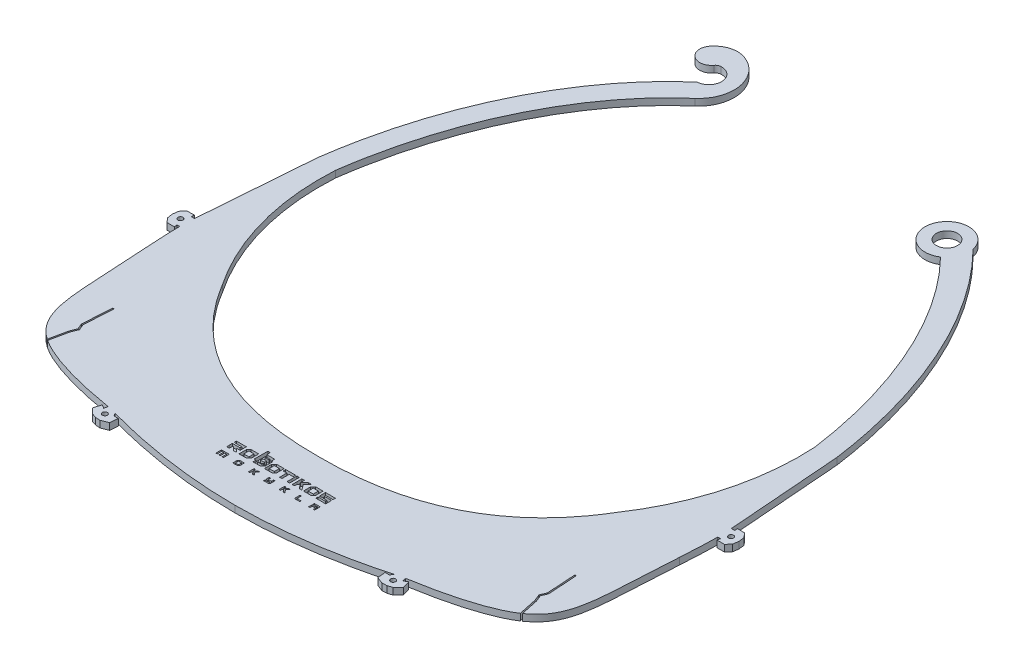
from build123d import *

# Parameters (mm, degrees)
SKETCH2_R           = 0.75
SKETCH2_R_2         = 3.169794379
BOSS_EXTRUDE2_DEPTH = 2
CUT_EXTRUDE1_DEPTH  = 1
CUT_EXTRUDE2_DEPTH  = 30


with BuildPart() as part:
    # Sketch2 → Boss-Extrude2 (new body)
    with BuildSketch(Plane(origin=(0, 0, 0), x_dir=(1, 0, 0), z_dir=(0, 1, 0))):
        with BuildLine():
            Line((-145.774014845, 4699.790846236), (-145.679424713, 4700.667060475))
            Line((-145.679424713, 4700.667060475), (-147.918372484, 4700.606196913))
            Line((-147.918372484, 4700.606196913), (-149.027988208, 4699.255761252))
            Line((-149.027988208, 4699.255761252), (-149.222790895, 4697.597182293))
            Line((-149.222790895, 4697.597182293), (-148.98298998, 4695.944509376))
            Line((-148.98298998, 4695.944509376), (-147.837087324, 4694.624725063))
            Line((-147.837087324, 4694.624725063), (-145.597312449, 4694.624725063))
            Line((-145.597312449, 4694.624725063), (-145.773758332, 4695.519138342))
            Line((-145.773758332, 4695.519138342), (-144.93974364, 4695.519138342))
            add(Edge.make_bspline(
                [(-144.46397827, 4684.514714632), (-144.606093665, 4687.588466409), (-144.901928293, 4691.324791696), (-144.93974364, 4695.519138342)],
                knots=[0.004734857, 0.004734857, 0.004734857, 0.004734857, 0.035161677, 0.035161677, 0.035161677, 0.035161677], degree=3))
            add(Edge.make_bspline(
                [(-108.903375625, 4638.035656948), (-118.821969125, 4639.685871765), (-132.493488743, 4643.060373116), (-144.218775593, 4654.394416396), (-143.099113193, 4666.334603474), (-144.46397827, 4684.514714632)],
                knots=[0.018902136, 0.018902136, 0.018902136, 0.018902136, 0.394121885, 0.490994555, 0.987628845, 0.987628845, 0.987628845, 0.987628845], degree=3))
            Line((-108.903375625, 4638.035656948), (-109.111012106, 4636.936921529))
            Line((-109.111012106, 4636.936921529), (-110.228421491, 4637.612566847))
            Line((-110.228421491, 4637.612566847), (-110.904437831, 4635.297018365))
            Line((-110.904437831, 4635.297018365), (-109.31209767, 4633.795971308))
            Line((-109.31209767, 4633.795971308), (-107.959504664, 4633.340434244))
            Line((-107.959504664, 4633.340434244), (-106.534299374, 4633.264199495))
            Line((-106.534299374, 4633.264199495), (-104.500152189, 4634.07100473))
            Line((-104.500152189, 4634.07100473), (-104.273152305, 4636.472511323))
            Line((-104.273152305, 4636.472511323), (-105.57754023, 4636.472511323))
            Line((-105.57754023, 4636.472511323), (-106.108269156, 4637.355076027))
            add(Edge.make_bspline(
                [(-64.303390576, 4631.426207785), (-78.229594734, 4631.453371402), (-92.531802759, 4633.559092847), (-106.108269156, 4637.355076027)],
                knots=[0.500293183, 0.500293183, 0.500293183, 0.500293183, 0.981944699, 0.981944699, 0.981944699, 0.981944699], degree=3))
            add(Edge.make_bspline(
                [(-64.303390576, 4631.426207785), (-50.377186419, 4631.453371402), (-36.074978393, 4633.559092847), (-22.498511996, 4637.355076027)],
                knots=[0.500293183, 0.500293183, 0.500293183, 0.500293183, 0.981944699, 0.981944699, 0.981944699, 0.981944699], degree=3))
            Line((-22.498511996, 4637.355076027), (-23.029240922, 4636.472511323))
            Line((-23.029240922, 4636.472511323), (-24.333628848, 4636.472511323))
            Line((-24.333628848, 4636.472511323), (-24.106628964, 4634.07100473))
            Line((-24.106628964, 4634.07100473), (-22.072481779, 4633.264199495))
            Line((-22.072481779, 4633.264199495), (-20.647276489, 4633.340434244))
            Line((-20.647276489, 4633.340434244), (-19.294683483, 4633.795971308))
            Line((-19.294683483, 4633.795971308), (-17.702343322, 4635.297018365))
            Line((-17.702343322, 4635.297018365), (-18.378359662, 4637.612566847))
            Line((-18.378359662, 4637.612566847), (-19.495769046, 4636.936921529))
            Line((-19.495769046, 4636.936921529), (-19.703405528, 4638.035656948))
            add(Edge.make_bspline(
                [(-19.703405528, 4638.035656948), (-9.784812028, 4639.685871765), (3.88670759, 4643.060373116), (15.611994441, 4654.394416396), (14.49233204, 4666.334603474), (15.857197118, 4684.514714632)],
                knots=[0.018902136, 0.018902136, 0.018902136, 0.018902136, 0.394121885, 0.490994555, 0.987628845, 0.987628845, 0.987628845, 0.987628845], degree=3))
            add(Edge.make_bspline(
                [(15.857197118, 4684.514714632), (15.999312513, 4687.588466409), (16.29514714, 4691.324791696), (16.332962487, 4695.519138342)],
                knots=[0.004734857, 0.004734857, 0.004734857, 0.004734857, 0.035161677, 0.035161677, 0.035161677, 0.035161677], degree=3))
            Line((16.332962487, 4695.519138342), (17.166977179, 4695.519138342))
            Line((17.166977179, 4695.519138342), (16.990531296, 4694.624725063))
            Line((16.990531296, 4694.624725063), (19.230306172, 4694.624725063))
            Line((19.230306172, 4694.624725063), (20.376208827, 4695.944509376))
            Line((20.376208827, 4695.944509376), (20.616009742, 4697.597182293))
            Line((20.616009742, 4697.597182293), (20.421207056, 4699.255761252))
            Line((20.421207056, 4699.255761252), (19.311591332, 4700.606196913))
            Line((19.311591332, 4700.606196913), (17.072643561, 4700.667060475))
            Line((17.072643561, 4700.667060475), (17.167233693, 4699.790846236))
            Line((17.167233693, 4699.790846236), (16.143581312, 4699.790846236))
            Line((16.143581312, 4699.790846236), (13.505704616, 4734.046734393))
            add(Edge.make_bspline(
                [(-20.140377949, 4808.505435192), (-19.339215101, 4807.69878822), (-16.169205429, 4804.385156989), (-10.959428961, 4798.073334595), (-4.937431717, 4789.049110006), (0.359464838, 4779.225886251), (4.896611241, 4768.706679247), (8.641256086, 4757.60156043), (11.078840538, 4747.950225277), (12.60715411, 4740.056303981), (13.230863748, 4736.050334581), (13.505704616, 4734.046734393)],
                knots=[-2.547822097, -2.547822097, -2.547822097, -2.547822097, -2.512682102, -2.406957035, -2.301231967, -2.1955069, -2.089781833, -1.984056766, -1.878331699, -1.825469165, -1.772606631, -1.772606631, -1.772606631, -1.772606631], degree=3))
            ThreePointArc((-20.140377949, 4808.505435192), (-32.664266502, 4809.623514522), (-22.989188291, 4801.592901377))
            add(Edge.make_bspline(
                [(7.531205359, 4733.448618243), (1.49518461, 4776.711269913), (-22.989188291, 4801.592901377)],
                knots=[1.775964024, 1.775964024, 1.775964024, 2.543499924, 2.543499924, 2.543499924], degree=2, weights=[1, 0.927260437, 1]))
            ThreePointArc((7.531205359, 4733.448618243), (4.986516441, 4708.998918893), (-5.29304341, 4686.669702846))
            add(Edge.make_bspline(
                [(-64.303390576, 4656.572608608), (-23.423446833, 4656.293379669), (-5.29304341, 4686.669702846)],
                knots=[0, 0, 0, 1, 1, 1], degree=2))
            add(Edge.make_bspline(
                [(-64.303390576, 4656.572608608), (-105.18333432, 4656.293379669), (-123.313737743, 4686.669702846)],
                knots=[0, 0, 0, 1, 1, 1], degree=2))
            ThreePointArc((-123.313737743, 4686.669702846), (-133.593297594, 4708.998918893), (-136.137986511, 4733.448618243))
            add(Edge.make_bspline(
                [(-100.963860647, 4805.950790548), (-129.440493439, 4781.452315035), (-136.137986511, 4733.448618243)],
                knots=[3.66477814, 3.66477814, 3.66477814, 4.507221283, 4.507221283, 4.507221283], degree=2, weights=[1, 0.912590151, 1]))
            ThreePointArc((-100.963860647, 4805.950790548), (-97.422627424, 4815.929347659), (-104.224712723, 4824.043752771))
            ThreePointArc((-104.224712723, 4824.043752771), (-108.705347231, 4824.182862669), (-112.368006092, 4821.59822203))
            ThreePointArc((-112.368006092, 4821.59822203), (-111.611928523, 4816.659274376), (-106.672980869, 4817.415351945))
            ThreePointArc((-106.672980869, 4817.415351945), (-106.103107375, 4817.914471202), (-105.375761358, 4818.126234287))
            ThreePointArc((-105.375761358, 4818.126234287), (-101.312817548, 4814.562168737), (-104.876883098, 4810.499224928))
            add(Edge.make_bspline(
                [(-104.876883098, 4810.499224928), (-106.096560831, 4809.44993496), (-108.458644854, 4807.290890126), (-113.03760026, 4802.595468236), (-118.390037321, 4796.115503959), (-124.190014325, 4787.432936271), (-129.311920423, 4777.946809151), (-133.714255465, 4767.757887709), (-137.358438688, 4756.975851357), (-139.737248923, 4747.587905934), (-141.231816337, 4739.902065904), (-141.842982215, 4735.998688424), (-142.112485768, 4734.046734393)],
                knots=[-2.618407168, -2.618407168, -2.618407168, -2.618407168, -2.5656247, -2.512842233, -2.407277298, -2.301712363, -2.196147428, -2.090582493, -1.985017558, -1.879452622, -1.826670155, -1.773887687, -1.773887687, -1.773887687, -1.773887687], degree=3))
            Line((-142.112485768, 4734.046734393), (-144.750362465, 4699.790846236))
            Line((-144.750362465, 4699.790846236), (-145.774014845, 4699.790846236))
        make_face()
        with Locations((-146.82022248, 4697.629831976)):
            Circle(SKETCH2_R, mode=Mode.SUBTRACT)
        with Locations((-107.515119617, 4635.661753265)):
            Circle(SKETCH2_R, mode=Mode.SUBTRACT)
        with Locations((-21.091661535, 4635.661753265)):
            Circle(SKETCH2_R, mode=Mode.SUBTRACT)
        with Locations((18.213441328, 4697.629831976)):
            Circle(SKETCH2_R, mode=Mode.SUBTRACT)
        with Locations((-26.576401525, 4807.114568719)):
            Circle(SKETCH2_R_2, mode=Mode.SUBTRACT)
    extrude(amount=BOSS_EXTRUDE2_DEPTH)

    # Sketch3 → Cut-Extrude1 (cut)
    with BuildSketch(Plane(origin=(0, 2, 0), x_dir=(1, 0, 0), z_dir=(0, 1, 0))):
        Polygon((-80.67831347, 4642.941212701), (-80.67831347, 4643.793212801), (-79.52631347, 4643.793212801), (-78.37431317, 4643.793212801), (-78.37431317, 4642.941212701), (-78.37431317, 4642.089212901), (-78.57831327, 4642.089212901), (-78.78231337, 4642.089212901), (-78.78231337, 4642.761212701), (-78.78231337, 4643.433212801), (-79.05831317, 4643.433212801), (-79.33431327, 4643.433212801), (-79.33431327, 4642.761212701), (-79.33431327, 4642.089212901), (-79.53831337, 4642.089212901), (-79.74231347, 4642.089212901), (-79.74231347, 4642.761212701), (-79.74231347, 4643.433212801), (-80.00631337, 4643.433212801), (-80.27031327, 4643.433212801), (-80.27031327, 4642.761212701), (-80.27031327, 4642.089212901), (-80.47431337, 4642.089212901), (-80.67831347, 4642.089212901), align=None)
        Polygon((-75.59031337, 4642.755775801), (-75.59031337, 4643.422338801), (-75.40378227, 4643.607775901), (-75.21725127, 4643.793212801), (-74.52778237, 4643.793212801), (-73.83831327, 4643.793212801), (-73.83831327, 4643.114611901), (-73.83831327, 4642.436011401), (-74.01287777, 4642.262612101), (-74.18744177, 4642.089212901), (-74.88887767, 4642.089212901), (-75.59031337, 4642.089212901), align=None)
        Polygon((-74.25831337, 4642.941212701), (-74.25831337, 4643.421212901), (-74.72031327, 4643.427729701), (-75.18231317, 4643.434249401), (-75.18231317, 4642.941212701), (-75.18231317, 4642.448176201), (-74.72031327, 4642.454695901), (-74.25831337, 4642.461212801), align=None, mode=Mode.SUBTRACT)
        with BuildLine():
            Line((-70.93431317, 4642.941212701), (-70.93431317, 4643.793212801))
            Line((-70.93431317, 4643.793212801), (-70.70631327, 4643.793212801))
            Line((-70.70631327, 4643.793212801), (-70.47831307, 4643.793212801))
            Line((-70.47831307, 4643.793212801), (-70.47831307, 4643.427503201))
            Line((-70.47831307, 4643.427503201), (-70.47831307, 4643.061793701))
            Line((-70.47831307, 4643.061793701), (-70.11203147, 4643.427503201))
            Line((-70.11203147, 4643.427503201), (-69.74574987, 4643.793212801))
            Line((-69.74574987, 4643.793212801), (-69.47106907, 4643.793212801))
            Line((-69.47106907, 4643.793212801), (-69.19638817, 4643.793212801))
            Line((-69.19638817, 4643.793212801), (-69.54935057, 4643.437411701))
            add(Edge.make_bspline(
                [(-69.54935057, 4643.437411701), (-69.74347987, 4643.241721401), (-69.90231307, 4643.074049301), (-69.90231307, 4643.064807501)],
                knots=[0, 0, 0, 0, 1, 1, 1, 1], degree=3))
            add(Edge.make_bspline(
                [(-69.90231307, 4643.064807501), (-69.90231307, 4643.055566501), (-69.74010867, 4642.832276101), (-69.54185867, 4642.568608401)],
                knots=[0, 0, 0, 0, 1, 1, 1, 1], degree=3))
            Line((-69.54185867, 4642.568608401), (-69.18140427, 4642.089212901))
            Line((-69.18140427, 4642.089212901), (-69.43985877, 4642.089921501))
            Line((-69.43985877, 4642.089921501), (-69.69831297, 4642.090630201))
            Line((-69.69831297, 4642.090630201), (-69.92631317, 4642.402879501))
            add(Edge.make_bspline(
                [(-69.92631317, 4642.402879501), (-70.05171307, 4642.574616801), (-70.16793917, 4642.733138401), (-70.18459387, 4642.755149901)],
                knots=[0, 0, 0, 0, 1, 1, 1, 1], degree=3))
            add(Edge.make_bspline(
                [(-70.18459387, 4642.755149901), (-70.21166477, 4642.790927701), (-70.23011207, 4642.780092001), (-70.35859377, 4642.652951301)],
                knots=[0, 0, 0, 0, 1, 1, 1, 1], degree=3))
            Line((-70.35859377, 4642.652951301), (-70.50231317, 4642.510731501))
            Line((-70.50231317, 4642.510731501), (-70.50231317, 4642.299980101))
            Line((-70.50231317, 4642.299980101), (-70.50231317, 4642.089229001))
            Line((-70.50231317, 4642.089229001), (-70.71831317, 4642.089229001))
            Line((-70.71831317, 4642.089229001), (-70.93431317, 4642.089229001))
            Line((-70.93431317, 4642.089229001), (-70.93431317, 4642.941212701))
        make_face()
        Polygon((-66.37431307, 4642.281212801), (-66.37431307, 4642.473212701), (-65.70231297, 4642.473212701), (-65.03031287, 4642.473212701), (-65.03031287, 4642.605212801), (-65.03031287, 4642.737212901), (-65.70231297, 4642.737212901), (-66.37431307, 4642.737212901), (-66.37431307, 4643.265212701), (-66.37431307, 4643.793212801), (-66.15831307, 4643.793212801), (-65.94231307, 4643.793212801), (-65.94231307, 4643.445212701), (-65.94231307, 4643.097212901), (-65.48631297, 4643.097212901), (-65.03031287, 4643.097212901), (-65.03031287, 4643.445212701), (-65.03031287, 4643.793212801), (-64.82631307, 4643.793212801), (-64.62231297, 4643.793212801), (-64.62231297, 4643.126649801), (-64.62231297, 4642.460086601), (-64.80884367, 4642.274649701), (-64.99537497, 4642.089212901), (-65.68484387, 4642.089212901), (-66.37431307, 4642.089212901), align=None)
        with BuildLine():
            Line((-61.76631307, 4642.941212701), (-61.76631307, 4643.793212801))
            Line((-61.76631307, 4643.793212801), (-61.53831397, 4643.793212801))
            Line((-61.53831397, 4643.793212801), (-61.31031207, 4643.793212801))
            Line((-61.31031207, 4643.793212801), (-61.31031207, 4643.431095001))
            Line((-61.31031207, 4643.431095001), (-61.31031207, 4643.068977301))
            Line((-61.31031207, 4643.068977301), (-60.93231207, 4643.430671201))
            Line((-60.93231207, 4643.430671201), (-60.55431207, 4643.792365201))
            Line((-60.55431207, 4643.792365201), (-60.29417947, 4643.792790401))
            Line((-60.29417947, 4643.792790401), (-60.03404977, 4643.793215601))
            Line((-60.03404977, 4643.793215601), (-60.37818137, 4643.430185701))
            add(Edge.make_bspline(
                [(-60.37818137, 4643.430185701), (-60.56745347, 4643.230519501), (-60.71943307, 4643.057179501), (-60.71591237, 4643.044985701)],
                knots=[0, 0, 0, 0, 1, 1, 1, 1], degree=3))
            add(Edge.make_bspline(
                [(-60.71591237, 4643.044985701), (-60.71106517, 4643.028196101), (-60.18086737, 4642.310719701), (-60.03178767, 4642.119215601)],
                knots=[0, 0, 0, 0, 1, 1, 1, 1], degree=3))
            add(Edge.make_bspline(
                [(-60.03178767, 4642.119215601), (-60.01341917, 4642.095634201), (-60.06285537, 4642.089215401), (-60.26281417, 4642.089215401)],
                knots=[0, 0, 0, 0, 1, 1, 1, 1], degree=3))
            Line((-60.26281417, 4642.089215401), (-60.51718957, 4642.089215401))
            Line((-60.51718957, 4642.089215401), (-60.76060627, 4642.419215501))
            add(Edge.make_bspline(
                [(-60.76060627, 4642.419215501), (-60.89448657, 4642.600715601), (-61.01153197, 4642.757467301), (-61.02070767, 4642.767552901)],
                knots=[0, 0, 0, 0, 1, 1, 1, 1], degree=3))
            add(Edge.make_bspline(
                [(-61.02070767, 4642.767552901), (-61.02989197, 4642.777638601), (-61.10419647, 4642.725432401), (-61.18585127, 4642.651539101)],
                knots=[0, 0, 0, 0, 1, 1, 1, 1], degree=3))
            Line((-61.18585127, 4642.651539101), (-61.33431307, 4642.517186301))
            Line((-61.33431307, 4642.517186301), (-61.33431307, 4642.303200001))
            Line((-61.33431307, 4642.303200001), (-61.33431307, 4642.089213701))
            Line((-61.33431307, 4642.089213701), (-61.55031307, 4642.089213701))
            Line((-61.55031307, 4642.089213701), (-61.76631307, 4642.089213701))
            Line((-61.76631307, 4642.089213701), (-61.76631307, 4642.941212701))
        make_face()
        Polygon((-57.13431207, 4642.941212701), (-57.13431207, 4643.793212801), (-56.93031397, 4643.793212801), (-56.72631307, 4643.793212801), (-56.72631307, 4643.133212901), (-56.72631307, 4642.473212701), (-56.12631207, 4642.473212701), (-55.52631397, 4642.473212701), (-55.52631397, 4642.281212801), (-55.52631397, 4642.089212901), (-56.33031307, 4642.089212901), (-57.13431207, 4642.089212901), align=None)
        Polygon((-52.83831307, 4642.593212901), (-52.83831307, 4643.097212901), (-52.17831117, 4643.097212901), (-51.51831207, 4643.097212901), (-51.51831207, 4643.241212901), (-51.51831207, 4643.385212901), (-52.17831117, 4643.385212901), (-52.83831307, 4643.385212901), (-52.83831307, 4643.589212701), (-52.83831307, 4643.793212801), (-51.96231117, 4643.793212801), (-51.08631207, 4643.793212801), (-51.08631207, 4642.941212701), (-51.08631207, 4642.089212901), (-51.27831117, 4642.089212901), (-51.47031307, 4642.089212901), (-51.47031307, 4642.413212901), (-51.47031307, 4642.737212901), (-51.93831307, 4642.737212901), (-52.40631307, 4642.737212901), (-52.40631307, 4642.413212901), (-52.40631307, 4642.089212901), (-52.62231307, 4642.089212901), (-52.83831307, 4642.089212901), align=None)
        with BuildLine():
            Line((-80.72631227, 4646.257212901), (-80.72631227, 4647.105212801))
            Line((-80.72631227, 4647.105212801), (-79.57431227, 4647.105212801))
            Line((-79.57431227, 4647.105212801), (-78.42231227, 4647.105212801))
            Line((-78.42231227, 4647.105212801), (-78.42231227, 4647.356980101))
            Line((-78.42231227, 4647.356980101), (-78.42231227, 4647.608747301))
            Line((-78.42231227, 4647.608747301), (-79.56831217, 4647.614980701))
            Line((-79.56831217, 4647.614980701), (-80.71431227, 4647.621214101))
            Line((-80.71431227, 4647.621214101), (-80.72097087, 4647.963214101))
            Line((-80.72097087, 4647.963214101), (-80.72762947, 4648.305214101))
            Line((-80.72762947, 4648.305214101), (-79.23897057, 4648.305214101))
            Line((-79.23897057, 4648.305214101), (-77.75031157, 4648.305214101))
            Line((-77.75031157, 4648.305214101), (-77.75031157, 4647.365421401))
            Line((-77.75031157, 4647.365421401), (-77.75031157, 4646.425628901))
            Line((-77.75031157, 4646.425628901), (-78.28321507, 4646.440524901))
            Line((-78.28321507, 4646.440524901), (-78.81611847, 4646.455421001))
            Line((-78.81611847, 4646.455421001), (-78.27741507, 4645.916318501))
            Line((-78.27741507, 4645.916318501), (-77.73871167, 4645.377215601))
            Line((-77.73871167, 4645.377215601), (-78.20429907, 4645.377215601))
            Line((-78.20429907, 4645.377215601), (-78.66988447, 4645.377215601))
            Line((-78.66988447, 4645.377215601), (-79.20124337, 4645.905212901))
            add(Edge.make_bspline(
                [(-79.20124337, 4645.905212901), (-79.70063397, 4646.401446801), (-79.73791947, 4646.433212701), (-79.82098957, 4646.433212701)],
                knots=[0, 0, 0, 0, 1, 1, 1, 1], degree=3))
            Line((-79.82098957, 4646.433212701), (-79.90937727, 4646.433212701))
            Line((-79.90937727, 4646.433212701), (-79.91584597, 4645.911212701))
            Line((-79.91584597, 4645.911212701), (-79.92231457, 4645.389212701))
            Line((-79.92231457, 4645.389212701), (-80.30774197, 4645.382639101))
            add(Edge.make_bspline(
                [(-80.30774197, 4645.382639101), (-80.51972697, 4645.379025001), (-80.70062697, 4645.383517901), (-80.70974087, 4645.392640101)],
                knots=[0, 0, 0, 0, 1, 1, 1, 1], degree=3))
            add(Edge.make_bspline(
                [(-80.70974087, 4645.392640101), (-80.71885427, 4645.401756301), (-80.72631227, 4645.790812501), (-80.72631227, 4646.257212901)],
                knots=[0, 0, 0, 0, 1, 1, 1, 1], degree=3))
        make_face()
        Polygon((-77.00631317, 4646.475503101), (-77.00631317, 4647.573793601), (-76.64003157, 4647.939503101), (-76.27375027, 4648.305212701), (-75.15203177, 4648.305212701), (-74.03031317, 4648.305212701), (-74.03031317, 4647.218931401), (-74.03031317, 4646.132650101), (-74.40858607, 4645.754931601), (-74.78685907, 4645.377212801), (-75.89658597, 4645.377212801), (-77.00631317, 4645.377212801), align=None)
        Polygon((-74.75031317, 4646.841212601), (-74.75031317, 4647.609212801), (-75.51831337, 4647.609212801), (-76.28631317, 4647.609212801), (-76.28631317, 4646.841212601), (-76.28631317, 4646.073212701), (-75.51831337, 4646.073212701), (-74.75031317, 4646.073212701), align=None, mode=Mode.SUBTRACT)
        Polygon((-69.39831307, 4646.475503101), (-69.39831307, 4647.573793601), (-69.03203147, 4647.939503101), (-68.66574987, 4648.305212701), (-67.54403157, 4648.305212701), (-66.42231297, 4648.305212701), (-66.42231297, 4647.218931401), (-66.42231297, 4646.132650101), (-66.80058587, 4645.754931601), (-67.17885857, 4645.377212801), (-68.28858587, 4645.377212801), (-69.39831307, 4645.377212801), align=None)
        Polygon((-67.14231297, 4646.841212601), (-67.14231297, 4647.609212801), (-67.91031317, 4647.609212801), (-68.67831307, 4647.609212801), (-68.67831307, 4646.841212601), (-68.67831307, 4646.073212701), (-67.91031317, 4646.073212701), (-67.14231297, 4646.073212701), align=None, mode=Mode.SUBTRACT)
        Polygon((-64.86231307, 4646.469212701), (-64.86231307, 4647.561212601), (-65.41431297, 4647.561212601), (-65.96631287, 4647.561212601), (-65.96631287, 4647.933212801), (-65.96631287, 4648.305212701), (-64.47831297, 4648.305212701), (-62.99031277, 4648.305212701), (-62.99031277, 4647.933212801), (-62.99031277, 4647.561212601), (-63.57831297, 4647.561212601), (-64.16631287, 4647.561212601), (-64.16631287, 4646.469212701), (-64.16631287, 4645.377212801), (-64.51431297, 4645.377212801), (-64.86231307, 4645.377212801), align=None)
        Polygon((-62.60631297, 4646.840603401), (-62.60631297, 4648.305212701), (-62.22212687, 4648.305212701), (-61.83794167, 4648.305212701), (-61.84412127, 4646.847212701), (-61.85030077, 4645.389212701), (-62.22830157, 4645.382602301), (-62.60630157, 4645.375991901), align=None)
        with BuildLine():
            Line((-61.09431207, 4646.840579301), (-61.09431207, 4648.305212701))
            Line((-61.09431207, 4648.305212701), (-60.72271837, 4648.305212701))
            Line((-60.72271837, 4648.305212701), (-60.35112187, 4648.305212701))
            Line((-60.35112187, 4648.305212701), (-60.34471557, 4647.691607101))
            Line((-60.34471557, 4647.691607101), (-60.33830927, 4647.078001901))
            Line((-60.33830927, 4647.078001901), (-59.70990797, 4647.692154801))
            Line((-59.70990797, 4647.692154801), (-59.08150677, 4648.306308001))
            Line((-59.08150677, 4648.306308001), (-58.64190707, 4648.299759901))
            Line((-58.64190707, 4648.299759901), (-58.20231017, 4648.293211901))
            Line((-58.20231017, 4648.293211901), (-58.81347397, 4647.674236401))
            add(Edge.make_bspline(
                [(-58.81347397, 4647.674236401), (-59.38789787, 4647.092471301), (-59.42272717, 4647.052200101), (-59.39283867, 4647.004342501)],
                knots=[0, 0, 0, 0, 1, 1, 1, 1], degree=3))
            add(Edge.make_bspline(
                [(-59.39283867, 4647.004342501), (-59.37534897, 4646.976336201), (-59.10302457, 4646.609749001), (-58.78767587, 4646.189701901)],
                knots=[0, 0, 0, 0, 1, 1, 1, 1], degree=3))
            add(Edge.make_bspline(
                [(-58.78767587, 4646.189701901), (-58.47232437, 4645.769654701), (-58.21430927, 4645.415006801), (-58.21430927, 4645.401595601)],
                knots=[0, 0, 0, 0, 1, 1, 1, 1], degree=3))
            add(Edge.make_bspline(
                [(-58.21430927, 4645.401595601), (-58.21430927, 4645.386109901), (-58.35319837, 4645.377211901), (-58.59495677, 4645.377211901)],
                knots=[0, 0, 0, 0, 1, 1, 1, 1], degree=3))
            Line((-58.59495677, 4645.377211901), (-58.97560437, 4645.377211901))
            Line((-58.97560437, 4645.377211901), (-59.42895777, 4645.988569301))
            add(Edge.make_bspline(
                [(-59.42895777, 4645.988569301), (-59.67830167, 4646.324816101), (-59.89026797, 4646.600216101), (-59.89999647, 4646.600569301)],
                knots=[0, 0, 0, 0, 1, 1, 1, 1], degree=3))
            add(Edge.make_bspline(
                [(-59.89999647, 4646.600569301), (-59.90971937, 4646.600909501), (-60.01772217, 4646.506711901), (-60.13999457, 4646.391211701)],
                knots=[0, 0, 0, 0, 1, 1, 1, 1], degree=3))
            Line((-60.13999457, 4646.391211701), (-60.36231017, 4646.181211801))
            Line((-60.36231017, 4646.181211801), (-60.37430077, 4645.785211801))
            Line((-60.37430077, 4645.785211801), (-60.38629127, 4645.389211801))
            Line((-60.38629127, 4645.389211801), (-60.74029037, 4645.382570301))
            Line((-60.74029037, 4645.382570301), (-61.09428937, 4645.375928701))
            Line((-61.09428937, 4645.375928701), (-61.09431207, 4646.840579301))
        make_face()
        Polygon((-57.71031207, 4646.475511301), (-57.71031207, 4647.573801501), (-57.34403047, 4647.939511301), (-56.97774897, 4648.305212701), (-55.85603147, 4648.305212701), (-54.73431397, 4648.305212701), (-54.73431397, 4647.218931401), (-54.73431397, 4646.132650101), (-55.11258607, 4645.754931601), (-55.49085827, 4645.377212801), (-56.60058517, 4645.377212801), (-57.71031207, 4645.377212801), align=None)
        Polygon((-55.45431397, 4646.841212601), (-55.45431397, 4647.609212801), (-56.22231307, 4647.609212801), (-56.99031207, 4647.609212801), (-56.99031207, 4646.841212601), (-56.99031207, 4646.073212701), (-56.22231307, 4646.073212701), (-55.45431397, 4646.073212701), align=None, mode=Mode.SUBTRACT)
        with BuildLine():
            Line((-54.01432817, 4645.717212901), (-54.01432817, 4646.025212801))
            Line((-54.01432817, 4646.025212801), (-52.87432717, 4646.025212801))
            Line((-52.87432717, 4646.025212801), (-51.73432627, 4646.025212801))
            Line((-51.73432627, 4646.025212801), (-51.73432627, 4646.240977801))
            Line((-51.73432627, 4646.240977801), (-51.73432627, 4646.456742801))
            Line((-51.73432627, 4646.456742801), (-52.86832627, 4646.462979001))
            Line((-52.86832627, 4646.462979001), (-54.00232627, 4646.469212401))
            Line((-54.00232627, 4646.469212401), (-54.00861917, 4647.387212401))
            Line((-54.00861917, 4647.387212401), (-54.01491207, 4648.305212401))
            Line((-54.01491207, 4648.305212401), (-52.52662677, 4648.305212401))
            Line((-52.52662677, 4648.305212401), (-51.03834137, 4648.305212401))
            Line((-51.03834137, 4648.305212401), (-51.03834137, 4647.933212501))
            Line((-51.03834137, 4647.933212501), (-51.03834137, 4647.561212301))
            Line((-51.03834137, 4647.561212301), (-52.13034047, 4647.561212301))
            Line((-52.13034047, 4647.561212301), (-53.22233947, 4647.561212301))
            Line((-53.22233947, 4647.561212301), (-53.22233947, 4647.357212501))
            Line((-53.22233947, 4647.357212501), (-53.22233947, 4647.153212401))
            Line((-53.22233947, 4647.153212401), (-52.13034047, 4647.153212401))
            Line((-52.13034047, 4647.153212401), (-51.03834137, 4647.153212401))
            Line((-51.03834137, 4647.153212401), (-51.03834137, 4646.265212301))
            Line((-51.03834137, 4646.265212301), (-51.03834137, 4645.377212501))
            Line((-51.03834137, 4645.377212501), (-52.51033887, 4645.377212501))
            add(Edge.make_bspline(
                [(-52.51033887, 4645.377212501), (-53.31994197, 4645.377212501), (-53.98954197, 4645.384412501), (-53.99834077, 4645.393211201)],
                knots=[0, 0, 0, 0, 1, 1, 1, 1], degree=3))
            add(Edge.make_bspline(
                [(-53.99834077, 4645.393211201), (-54.00712817, 4645.402011701), (-54.01432817, 4645.547812501), (-54.01432817, 4645.717212901)],
                knots=[0, 0, 0, 0, 1, 1, 1, 1], degree=3))
        make_face()
        Polygon((-72.83031327, 4645.833212901), (-72.83031327, 4646.265212601), (-73.10644707, 4646.265212601), (-73.38258127, 4646.265212601), (-73.37644707, 4648.323212701), (-73.37031297, 4650.381212801), (-73.00431287, 4650.387837301), (-72.63831277, 4650.394461901), (-72.63831277, 4649.865837001), (-72.63831277, 4649.337211901), (-71.46231297, 4649.337211901), (-70.28631287, 4649.337211901), (-70.28631287, 4648.833211901), (-70.28631287, 4648.329211901), (-70.09431267, 4648.329211901), (-69.90231277, 4648.329211901), (-69.90231277, 4647.194890201), (-69.90231277, 4646.060569001), (-70.23262327, 4645.730890401), (-70.56293427, 4645.401212001), (-71.69662337, 4645.401212001), (-72.83031297, 4645.401212001), align=None)
        with BuildLine():
            Line((-70.79031317, 4646.469212701), (-70.99325337, 4646.265212601))
            Line((-70.99325337, 4646.265212601), (-71.55178317, 4646.265212601))
            Line((-71.55178317, 4646.265212601), (-72.11031327, 4646.265212601))
            Line((-72.11031327, 4646.265212601), (-72.11031327, 4646.169212801))
            Line((-72.11031327, 4646.169212801), (-72.11031327, 4646.073212701))
            Line((-72.11031327, 4646.073212701), (-71.33031317, 4646.073212701))
            Line((-71.33031317, 4646.073212701), (-70.55031307, 4646.073212701))
            Line((-70.55031307, 4646.073212701), (-70.55031307, 4646.373212601))
            add(Edge.make_bspline(
                [(-70.55031307, 4646.373212601), (-70.55031307, 4646.538212801), (-70.55865257, 4646.673212801), (-70.56884307, 4646.673212801)],
                knots=[0, 0, 0, 0, 1, 1, 1, 1], degree=3))
            add(Edge.make_bspline(
                [(-70.56884307, 4646.673212801), (-70.57903367, 4646.673212801), (-70.67869617, 4646.581412801), (-70.79031317, 4646.469212701)],
                knots=[0, 0, 0, 0, 1, 1, 1, 1], degree=3))
        make_face(mode=Mode.SUBTRACT)
        Polygon((-71.00631317, 4647.321212801), (-71.00631317, 4647.657212701), (-71.55831307, 4647.657212701), (-72.11031327, 4647.657212701), (-72.11031327, 4647.321212801), (-72.11031327, 4646.985212601), (-71.55831307, 4646.985212601), (-71.00631317, 4646.985212601), align=None, mode=Mode.SUBTRACT)
        with BuildLine():
            Line((-71.00631317, 4648.473212801), (-71.00631317, 4648.617212801))
            Line((-71.00631317, 4648.617212801), (-71.58231317, 4648.617212801))
            Line((-71.58231317, 4648.617212801), (-72.15831317, 4648.617212801))
            Line((-72.15831317, 4648.617212801), (-72.15831317, 4648.489212601))
            add(Edge.make_bspline(
                [(-72.15831317, 4648.489212601), (-72.15831317, 4648.418812801), (-72.15111317, 4648.354012801), (-72.14231437, 4648.345212601)],
                knots=[0, 0, 0, 0, 1, 1, 1, 1], degree=3))
            add(Edge.make_bspline(
                [(-72.14231437, 4648.345212601), (-72.13351567, 4648.336413901), (-71.87431447, 4648.329213901), (-71.56631437, 4648.329213901)],
                knots=[0, 0, 0, 0, 1, 1, 1, 1], degree=3))
            Line((-71.56631437, 4648.329213901), (-71.00631457, 4648.329213901))
            Line((-71.00631457, 4648.329213901), (-71.00631317, 4648.473212801))
        make_face(mode=Mode.SUBTRACT)
    extrude(amount=-CUT_EXTRUDE1_DEPTH, mode=Mode.SUBTRACT)

    # Sketch5 → Cut-Extrude2 (cut)
    with BuildSketch(Plane(origin=(0, 2, 0), x_dir=(1, 0, 0), z_dir=(0, 1, 0))):
        Polygon((-136.202503175, 4643.151302747), (-134.386783175, 4651.708952531), (-133.608398699, 4653.71205026), (-134.321503175, 4655.422142437), (-134.037193175, 4660.109979957), (-133.749013175, 4664.291139957), (-133.330963175, 4664.284479957), (-133.619173175, 4660.103289957), (-133.888753175, 4655.472872436), (-133.198183175, 4653.845222477), (-133.126003175, 4653.683162481), (-133.228513175, 4653.533102485), (-133.969903175, 4651.623332533), (-135.790393175, 4643.064062749), align=None)
        Polygon((7.595722023, 4643.151302747), (7.183612023, 4643.064062749), (5.363122023, 4651.623332533), (4.621732023, 4653.533102485), (4.519222023, 4653.683162481), (4.591402023, 4653.845222477), (5.281972023, 4655.472872436), (5.012392023, 4660.103289957), (4.724182023, 4664.284479957), (5.142232023, 4664.291139957), (5.430412023, 4660.109979957), (5.714722023, 4655.422142437), (5.001617547, 4653.71205026), (5.780002023, 4651.708952531), align=None)
    extrude(amount=-CUT_EXTRUDE2_DEPTH, mode=Mode.SUBTRACT)


solid = part.part
